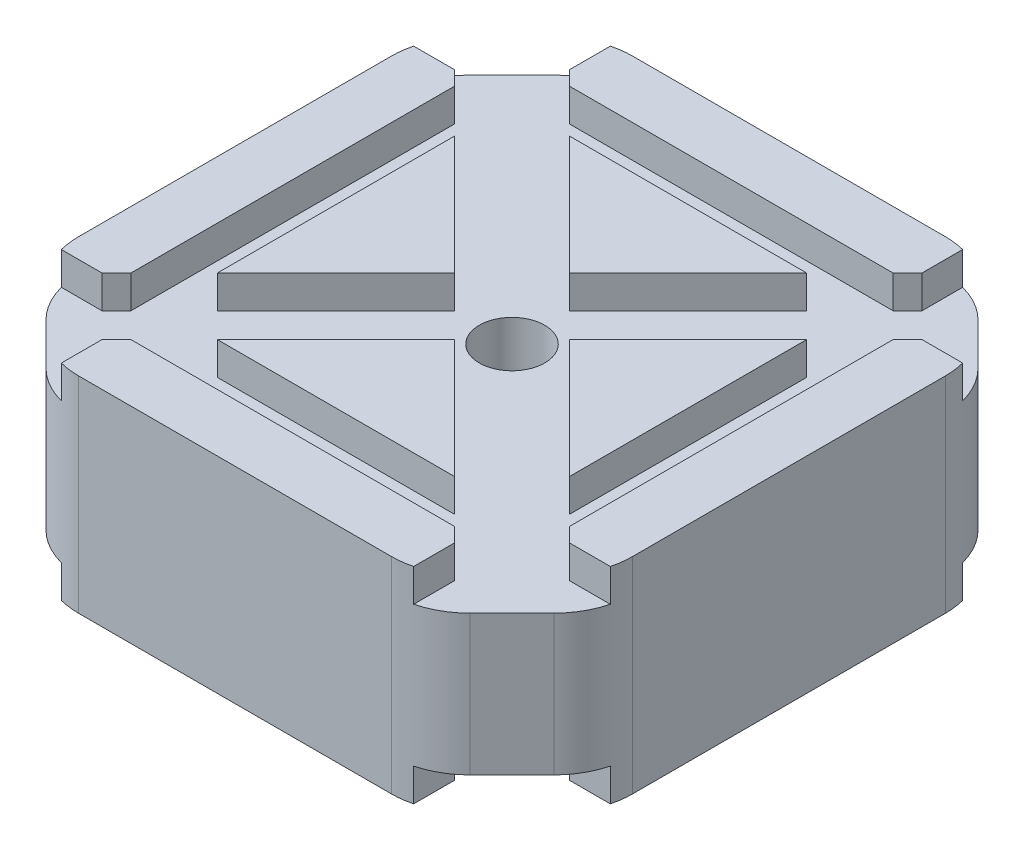
from build123d import *

# Parameters (mm, degrees)
BOSS_EXTRUDE1_DEPTH = 7.85
SKETCH18_W          = 3.3
SKETCH18_H          = 2.5
CUT_EXTRUDE10_DEPTH = 43.3
SKETCH19_W          = 3.3
SKETCH19_H          = 2.5
CUT_EXTRUDE11_DEPTH = 43.3
SKETCH20_W          = 6.221233688
SKETCH20_H          = 2.5
CUT_EXTRUDE12_DEPTH = 57.710616844
SKETCH21_W          = 6.221233688
SKETCH21_H          = 2.5
CUT_EXTRUDE13_DEPTH = 57.710616844
SKETCH22_R          = 2.5
CUT_EXTRUDE14_DEPTH = 6.35
CUT_EXTRUDE15_DEPTH = 14.2
FILLET8_R           = 6


with BuildPart() as part:
    # Sketch1 → Boss-Extrude1 (new body)
    with BuildSketch(Plane(origin=(0, 0, 0), x_dir=(1, 0, 0), z_dir=(0, 1, 0))):
        Polygon((-21.15, 16.750923472), (-16.750923472, 21.15), (16.750923472, 21.15), (21.15, 16.750923472), (21.15, -16.750923472), (16.750923472, -21.15), (-16.750923472, -21.15), (-21.15, -16.750923472), align=None)
    boss_extrude1 = extrude(amount=BOSS_EXTRUDE1_DEPTH)

    # Sketch18 → Cut-Extrude10 (cut, through all)
    with BuildSketch(Plane.XY.offset(21.15)):
        with Locations((15.100923472, 6.6)):
            Rectangle(SKETCH18_W, SKETCH18_H)
        with Locations((-15.100923472, 6.6)):
            Rectangle(SKETCH18_W, SKETCH18_H)
    cut_extrude10 = extrude(amount=-CUT_EXTRUDE10_DEPTH, mode=Mode.SUBTRACT)

    # Sketch19 → Cut-Extrude11 (cut, through all)
    with BuildSketch(Plane(origin=(21.15, 0, 0), x_dir=(0, 0, -1), z_dir=(1, 0, 0))):
        with Locations((-15.100923472, 6.6)):
            Rectangle(SKETCH19_W, SKETCH19_H)
        with Locations((15.100923472, 6.6)):
            Rectangle(SKETCH19_W, SKETCH19_H)
    cut_extrude11 = extrude(amount=-CUT_EXTRUDE11_DEPTH, mode=Mode.SUBTRACT)

    # Sketch20 → Cut-Extrude12 (cut, through all)
    with BuildSketch(Plane(origin=(18.950461736, 0, 18.950461736), x_dir=(0.707106781, 0, -0.707106781), z_dir=(0.707106781, 0, 0.707106781))):
        with Locations((0, 6.6)):
            Rectangle(SKETCH20_W, SKETCH20_H)
    cut_extrude12 = extrude(amount=-CUT_EXTRUDE12_DEPTH, mode=Mode.SUBTRACT)

    # Sketch21 → Cut-Extrude13 (cut, through all)
    with BuildSketch(Plane(origin=(-18.950461736, 0, 18.950461736), x_dir=(0.707106781, 0, 0.707106781), z_dir=(-0.707106781, 0, 0.707106781))):
        with Locations((0, 6.6)):
            Rectangle(SKETCH21_W, SKETCH21_H)
    cut_extrude13 = extrude(amount=-CUT_EXTRUDE13_DEPTH, mode=Mode.SUBTRACT)

    # Sketch22 → Cut-Extrude14 (cut, through all)
    with BuildSketch(Plane(origin=(0, 5.35, 0), x_dir=(1, 0, 0), z_dir=(0, 1, 0))):
        Circle(SKETCH22_R)
    cut_extrude14 = extrude(amount=-CUT_EXTRUDE14_DEPTH, mode=Mode.SUBTRACT)

    # Mirror1: Boss-Extrude1, Cut-Extrude10, Cut-Extrude11, Cut-Extrude12, Cut-Extrude13, Cut-Extrude14 across plane
    add(boss_extrude1.mirror(Plane(origin=(0, 0, 0), x_dir=(0, 0, 1), z_dir=(0, -1, 0))))
    add(cut_extrude10.mirror(Plane(origin=(0, 0, 0), x_dir=(0, 0, 1), z_dir=(0, -1, 0))), mode=Mode.SUBTRACT)
    add(cut_extrude11.mirror(Plane(origin=(0, 0, 0), x_dir=(0, 0, 1), z_dir=(0, -1, 0))), mode=Mode.SUBTRACT)
    add(cut_extrude12.mirror(Plane(origin=(0, 0, 0), x_dir=(0, 0, 1), z_dir=(0, -1, 0))), mode=Mode.SUBTRACT)
    add(cut_extrude13.mirror(Plane(origin=(0, 0, 0), x_dir=(0, 0, 1), z_dir=(0, -1, 0))), mode=Mode.SUBTRACT)
    add(cut_extrude14.mirror(Plane(origin=(0, 0, 0), x_dir=(0, 0, 1), z_dir=(0, -1, 0))), mode=Mode.SUBTRACT)

    # Sketch23 → Cut-Extrude15 (cut, through all)
    with BuildSketch(Plane(origin=(0, 5.35, 0), x_dir=(1, 0, 0), z_dir=(0, 1, 0))):
        Polygon((-21.15, -14.432485579), (-14.432485579, -21.15), (-16.750923472, -21.15), (-21.15, -16.750923472), align=None)
        Polygon((-21.15, 14.432485579), (-14.432485579, 21.15), (-16.750923472, 21.15), (-21.15, 16.750923472), align=None)
        Polygon((14.432485579, 21.15), (21.15, 14.432485579), (21.15, 16.750923472), (16.750923472, 21.15), align=None)
        Polygon((14.432485579, -21.15), (21.15, -14.432485579), (21.15, -16.750923472), (16.750923472, -21.15), align=None)
    extrude(amount=-CUT_EXTRUDE15_DEPTH, mode=Mode.SUBTRACT)

    # Fillet8
    fillet8_edges = [part.edges().sort_by_distance(p)[0] for p in [
        (14.432485579, 0, -21.15),
        (21.15, 0, -14.432485579),
        (-21.15, 0, -14.432485579),
        (-14.432485579, 0, -21.15),
        (-14.432485579, 0, 21.15),
        (-21.15, 0, 14.432485579),
        (21.15, 0, 14.432485579),
        (14.432485579, 0, 21.15),
    ]]
    fillet(fillet8_edges, radius=FILLET8_R)


solid = part.part
